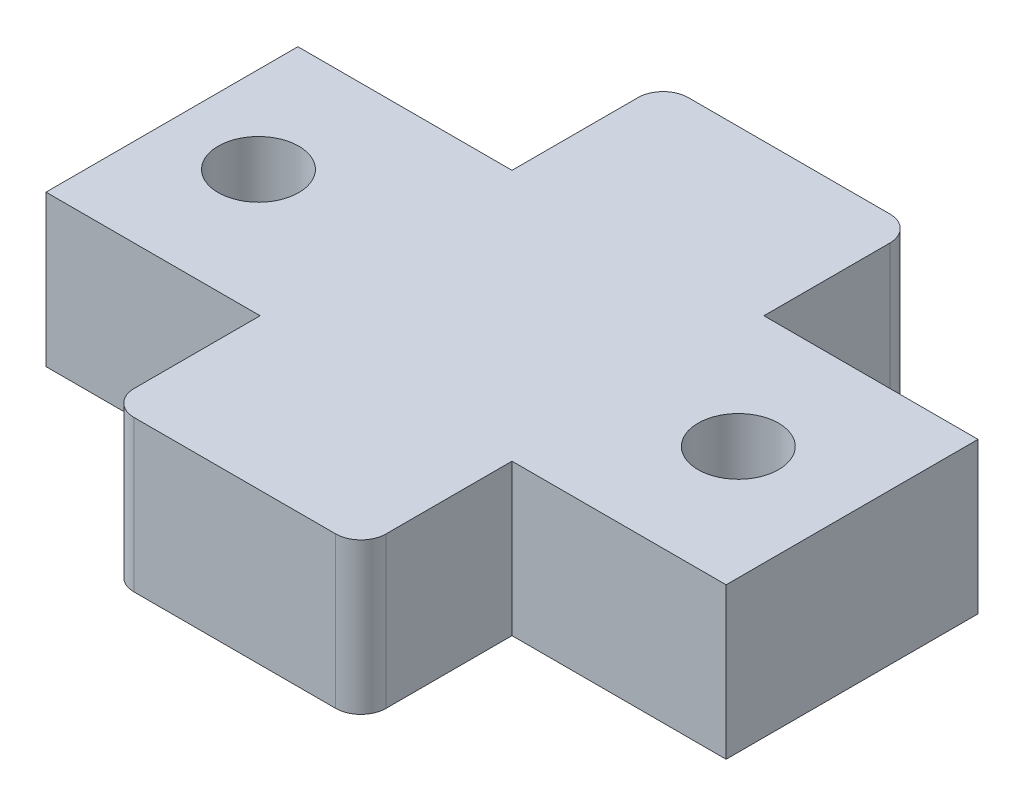
from build123d import *

# Parameters (mm, degrees)
SKETCH1_W              = 27
SKETCH1_H              = 10
BOSS_EXTRUDE1_DEPTH    = 6
M3_CLEARANCE_HOLE1_D   = 3.2
SKETCH234_W            = 10
SKETCH234_H            = 6
BOSS_EXTRUDE234_DEPTH  = 6
FILLET134_R            = 1
FILLET134_OF_MIRROR1_R = 1


with BuildPart() as part:
    # Sketch1 → Boss-Extrude1 (new body)
    with BuildSketch(Plane(origin=(0, 0, 0), x_dir=(1, 0, 0), z_dir=(0, 1, 0))):
        Rectangle(SKETCH1_W, SKETCH1_H)
    extrude(amount=BOSS_EXTRUDE1_DEPTH)

    # M3 Clearance Hole1 (through all)
    with Locations(Plane(origin=(0, 0, 0), x_dir=(-1, 0, 0), z_dir=(0, -1, 0))):
        with Locations((10.065, 0), (-8.985, 0)):
            Hole(M3_CLEARANCE_HOLE1_D / 2)

    # Sketch234 → Boss-Extrude234 (add)
    with BuildSketch(Plane(origin=(0.767778608, 6, 5), x_dir=(-1, 0, 0), z_dir=(0, 0, 1))):
        with Locations((0.767778608, 3)):
            Rectangle(SKETCH234_W, SKETCH234_H)
    boss_extrude234 = extrude(amount=BOSS_EXTRUDE234_DEPTH)

    # Fillet134
    fillet134_edges = [part.edges().sort_by_distance(p)[0] for p in [
        (5, 3, 11),
        (-5, 3, 11),
    ]]
    fillet(fillet134_edges, radius=FILLET134_R)

    # Mirror1: Boss-Extrude234 across plane
    add(boss_extrude234.mirror(Plane.XY))

    # Fillet134 of Mirror1
    fillet134_of_mirror1_edges = [part.edges().sort_by_distance(p)[0] for p in [
        (5, 3, -11),
        (-5, 3, -11),
    ]]
    fillet(fillet134_of_mirror1_edges, radius=FILLET134_OF_MIRROR1_R)


solid = part.part
